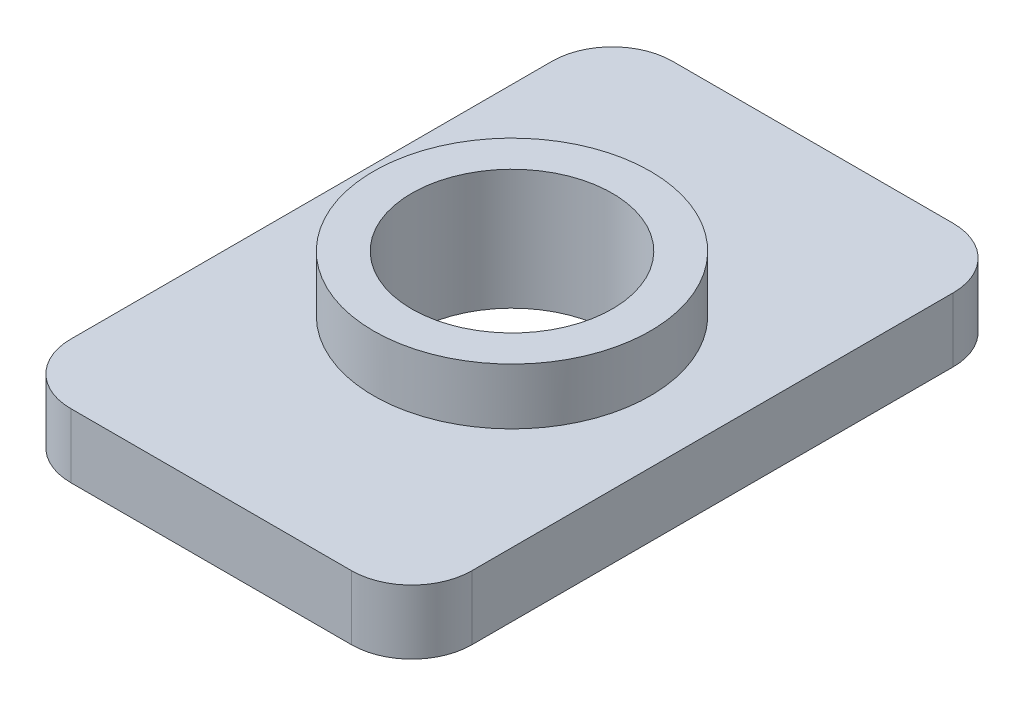
from build123d import *

# Parameters (mm, degrees)
SKETCH_1_W       = 10
SKETCH_1_H       = 15
SKETCH_1_R       = 2.5
BASE_DEPTH       = 1.6
FILLET_2_R       = 1.5
SKETCH_2_R       = 3.45
SKETCH_2_R_2     = 2.5
THREADBODY_DEPTH = 1.4


with BuildPart() as part:
    # Эскиз1 → Base (new body)
    with BuildSketch(Plane(origin=(0, 0, 0), x_dir=(1, 0, 0), z_dir=(0, 1, 0))):
        Rectangle(SKETCH_1_W, SKETCH_1_H)
        Circle(SKETCH_1_R, mode=Mode.SUBTRACT)
    extrude(amount=BASE_DEPTH)

    # Fillet 2
    fillet_2_edges = [part.edges().sort_by_distance(p)[0] for p in [
        (-5, 0.8, -7.5),
        (5, 0.8, -7.5),
        (5, 0.8, 7.5),
        (-5, 0.8, 7.5),
    ]]
    fillet(fillet_2_edges, radius=FILLET_2_R)

    # Эскиз2 → ThreadBody (add)
    with BuildSketch(Plane(origin=(0, 1.6, 0), x_dir=(1, 0, 0), z_dir=(0, 1, 0))):
        Circle(SKETCH_2_R)
        Circle(SKETCH_2_R_2, mode=Mode.SUBTRACT)
    extrude(amount=THREADBODY_DEPTH)


solid = part.part
